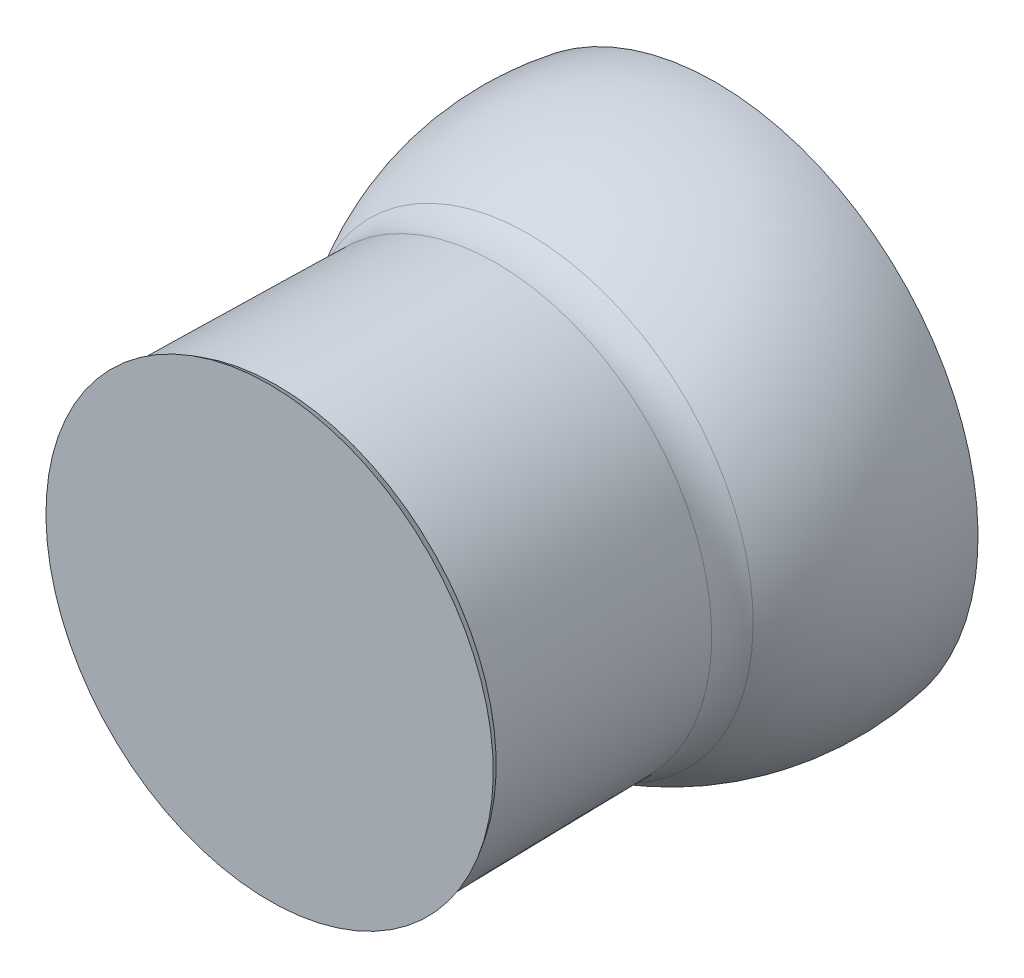
from build123d import *


with BuildPart() as part:
    # Sketch1 → Revolve1 (revolve)
    with BuildSketch(Plane(origin=(0, 0, 0), x_dir=(0, 0, -1), z_dir=(1, 0, 0))):
        with BuildLine():
            Line((0, 0), (-50.959835356, 0))
            Line((-50.959835356, 0), (-61.054255014, 0))
            Line((-61.054255014, 0), (-61.054255014, 30.599788402))
            Line((-61.054255014, 30.599788402), (-60.054255014, 30))
            Line((-60.054255014, 30), (-30.054255014, 29.5))
            ThreePointArc((-30.054255014, 29.5), (-27.754838856, 29.797720054), (-25.637373582, 30.742332522))
            ThreePointArc((-25.637373582, 30.742332522), (-22.902920152, 32.314145749), (-20.042663952, 33.643343571))
            ThreePointArc((-20.042663952, 33.643343571), (-10.179122164, 36.1760026), (0, 35.877187771))
            Line((0, 35.877187771), (0, 34.862194457))
            Line((0, 34.862194457), (0, 0))
        make_face()
    revolve(axis=Axis((0, 0, 0), (0, 0, 1)))


solid = part.part
